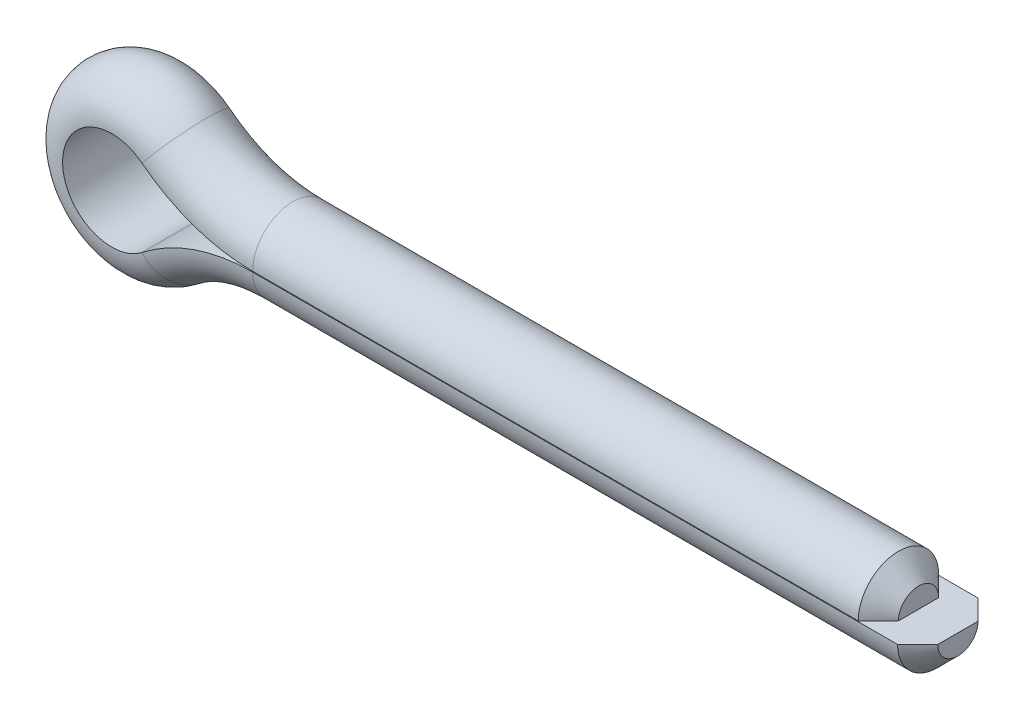
from build123d import *

# Parameters (mm, degrees)
CHAMFER1_SIZE = 1.42875


with BuildPart() as part:
    # Sweep1: sweep along a path in Sketch1
    with BuildLine(Plane.XY) as sweep1_path:
        Line((2.794, -0.0254), (-44.45, -0.0254))
        ThreePointArc((-44.45, -0.0254), (-48.605420273, -0.724463272), (-52.303375713, -2.744694118))
        ThreePointArc((-52.303375713, -2.744694118), (-57.955554034, 0), (-52.303375713, 2.744694118))
        ThreePointArc((-52.303375713, 2.744694118), (-48.605420273, 0.724463272), (-44.45, 0.0254))
        Line((-44.45, 0.0254), (0, 0.0254))
    # Sketch2 → Sweep1 (sweep)
    with BuildSketch(Plane(origin=(0, 0, 0), x_dir=(0, 0, -1), z_dir=(1, 0, 0))):
        with BuildLine():
            Line((-2.8575, 0.0254), (2.8575, 0.0254))
            ThreePointArc((2.8575, 0.0254), (0, 2.8829), (-2.8575, 0.0254))
        make_face()
    sweep(path=sweep1_path.line)

    # Chamfer1
    chamfer1_edges = [part.edges().sort_by_distance(p)[0] for p in [
        (2.794, -2.8829, 0),
        (0, 2.8829, 0),
    ]]
    chamfer(chamfer1_edges, length=CHAMFER1_SIZE)


solid = part.part
